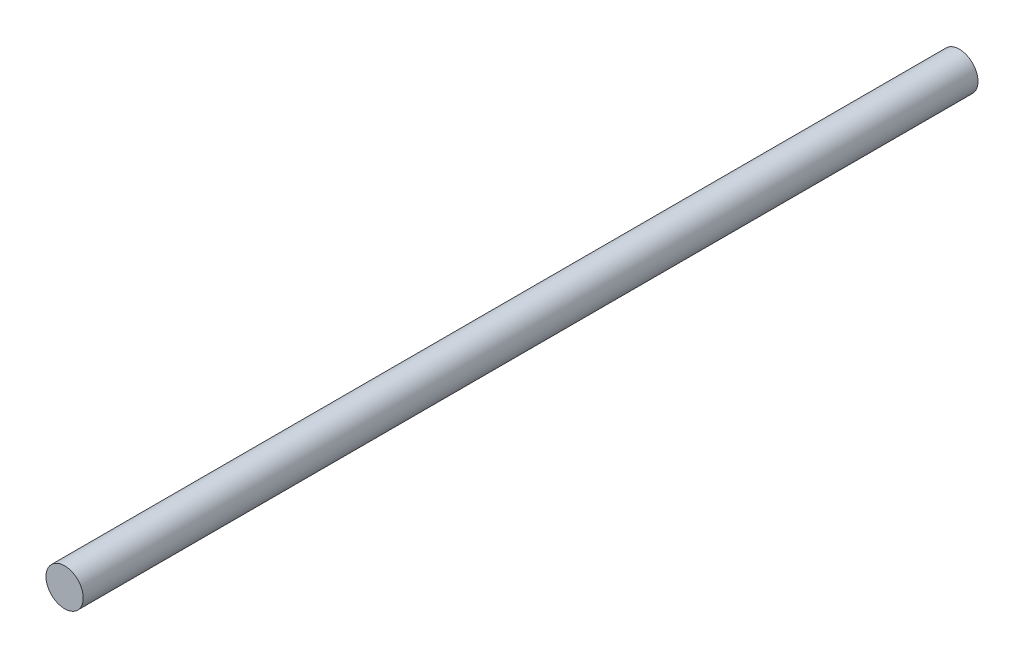
from build123d import *

# Parameters (mm, degrees)
SKETCH1_R           = 2.5
BOSS_EXTRUDE1_DEPTH = 120


with BuildPart() as part:
    # Sketch1 → Boss-Extrude1 (new body)
    with BuildSketch(Plane.XY):
        Circle(SKETCH1_R)
    extrude(amount=BOSS_EXTRUDE1_DEPTH)


solid = part.part
